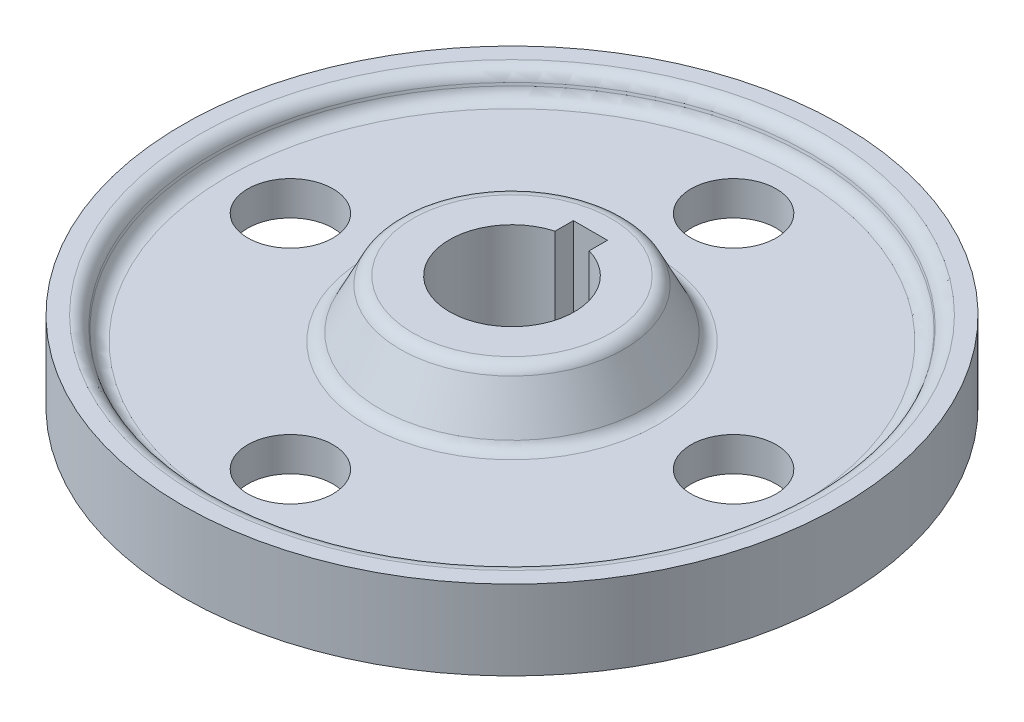
from build123d import *

# Parameters (mm, degrees)
SKETCH1_R           = 58
BOSS_EXTRUDE1_DEPTH = 13
SKETCH3_R           = 11
CUT_EXTRUDE1_DEPTH  = 84.048178788
SKETCH5_R           = 7.5
CUT_EXTRUDE2_DEPTH  = 84.048178788
SKETCH15_W          = 6
SKETCH15_H          = 5.6
CUT_EXTRUDE5_DEPTH  = 84.048178788
SKETCH16_R          = 60
SKETCH16_R_2        = 40
CUT_EXTRUDE6_DEPTH  = 6
FILLET1_R           = 2.5


with BuildPart() as part:
    # Sketch1 → Boss-Extrude1 (new body)
    with BuildSketch(Plane(origin=(0, 0, 0), x_dir=(1, 0, 0), z_dir=(0, 1, 0))):
        Circle(SKETCH1_R)
    extrude(amount=BOSS_EXTRUDE1_DEPTH)

    # Sketch3 → Cut-Extrude1 (cut, through all)
    with BuildSketch(Plane(origin=(0, 13, 0), x_dir=(1, 0, 0), z_dir=(0, 1, 0))):
        Circle(SKETCH3_R)
    extrude(amount=-CUT_EXTRUDE1_DEPTH, mode=Mode.SUBTRACT)

    # Sketch5 → Cut-Extrude2 (cut, through all)
    with BuildSketch(Plane(origin=(0, 13, 0), x_dir=(1, 0, 0), z_dir=(0, 1, 0))):
        with Locations((0, 39)):
            Circle(SKETCH5_R)
        with Locations((39, 0)):
            Circle(SKETCH5_R)
        with Locations((0, -39)):
            Circle(SKETCH5_R)
        with Locations((-39, 0)):
            Circle(SKETCH5_R)
    extrude(amount=-CUT_EXTRUDE2_DEPTH, mode=Mode.SUBTRACT)

    # Sketch14 → Cut-Revolve2 (revolve, cut)
    with BuildSketch(Plane.XY):
        Polygon((-52, 3), (-24, 3), (-19, 13), (-55, 13), align=None)
    revolve(axis=Axis((0, 14.3, 0), (0, -1, 0)), mode=Mode.SUBTRACT)

    # Sketch15 → Cut-Extrude5 (cut, through all)
    with BuildSketch(Plane(origin=(0, 13, 0), x_dir=(1, 0, 0), z_dir=(0, 1, 0))):
        with Locations((0, 11)):
            Rectangle(SKETCH15_W, SKETCH15_H)
    extrude(amount=-CUT_EXTRUDE5_DEPTH, mode=Mode.SUBTRACT)

    # Sketch16 → Cut-Extrude6 (cut)
    with BuildSketch(Plane(origin=(0, 13, 0), x_dir=(1, 0, 0), z_dir=(0, 1, 0))):
        Circle(SKETCH16_R)
        Circle(SKETCH16_R_2, mode=Mode.SUBTRACT)
    extrude(amount=-CUT_EXTRUDE6_DEPTH, mode=Mode.SUBTRACT)

    # Fillet1
    fillet1_edges = [part.edges().sort_by_distance(p)[0] for p in [
        (19, 13, 0),
        (24, 3, 0),
        (52, 3, 0),
        (53.2, 7, 0),
    ]]
    fillet(fillet1_edges, radius=FILLET1_R)

    # Mirror3: part across plane


with BuildPart() as part_1:
    add(part.part)
    add(part.part.mirror(Plane.ZX))


solid = part_1.part
